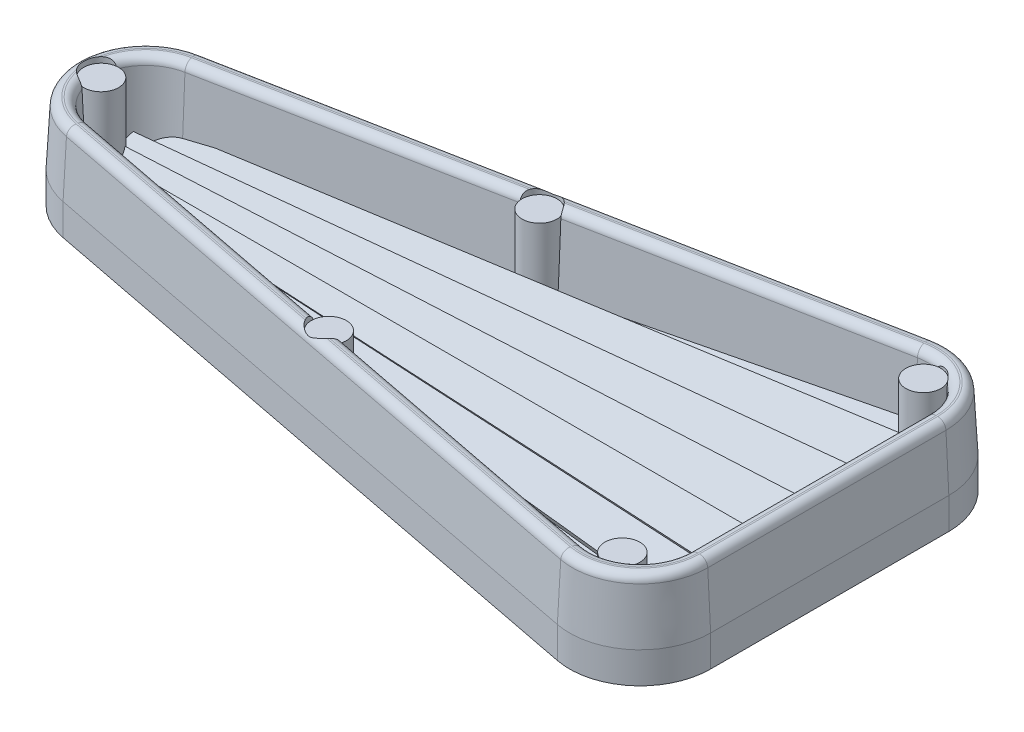
from build123d import *

# Parameters (mm, degrees)
BOSS_EXTRUDE1_DEPTH = 3.4544
CUT_EXTRUDE1_DEPTH  = 73.37481788
CUT_EXTRUDE2_DEPTH  = 73.37481788
CUT_EXTRUDE3_DEPTH  = 73.37481788
CUT_EXTRUDE4_DEPTH  = 73.37481788
EXTRUDE_THIN1_DEPTH = 6.35
DRAFT1_ANGLE        = -3
FILLET1_R           = 0.5588
SKETCH9_R           = 1.1811
BOSS_EXTRUDE2_DEPTH = 5.08
SKETCH10_R          = 1.1811
CUT_EXTRUDE5_DEPTH  = 0.381


with BuildPart() as part:
    # Sketch1 → Boss-Extrude1 (new body)
    with BuildSketch(Plane(origin=(0, 0, 0), x_dir=(1, 0, 0), z_dir=(0, 1, 0))):
        with BuildLine():
            Line((24.077556442, 4.675181972), (65.479556442, 12.714281972))
            ThreePointArc((65.479556442, 12.714281972), (69.417036576, 11.713657695), (71.149844843, 8.0391))
            Line((71.149844843, 8.0391), (71.149844843, -8.0391))
            ThreePointArc((71.149844843, -8.0391), (69.417036576, -11.713657695), (65.479556442, -12.714281972))
            Line((65.479556442, -12.714281972), (24.077556442, -4.675181972))
            ThreePointArc((24.077556442, -4.675181972), (20.222844843, 0), (24.077556442, 4.675181972))
        make_face()
    extrude(amount=BOSS_EXTRUDE1_DEPTH)

    # Sketch2 → Cut-Extrude1 (cut, through all)
    with BuildSketch(Plane(origin=(0, 0, 0), x_dir=(0, 0, -1), z_dir=(1, 0, 0))):
        Polygon((-1.905, 3.4544), (0, 1.5494), (1.905, 3.4544), align=None)
    extrude(amount=CUT_EXTRUDE1_DEPTH, mode=Mode.SUBTRACT)

    # Sketch3 → Cut-Extrude2 (cut, through all)
    with BuildSketch(Plane(origin=(0, 0, 0), x_dir=(-0.052335956242944376, 0, -0.9986295347545739), z_dir=(0.9986295347545738, 0, -0.05233595624294437))):
        Polygon((1.905, 3.4544), (-1.905, 3.4544), (0, 1.5494), align=None)
    cut_extrude2 = extrude(amount=CUT_EXTRUDE2_DEPTH, mode=Mode.SUBTRACT)

    # Sketch4 → Cut-Extrude3 (cut, through all)
    with BuildSketch(Plane(origin=(0, 0, 0), x_dir=(-0.1045284632676543, 0, -0.9945218953682733), z_dir=(0.9945218953682734, 0, -0.10452846326765432))):
        Polygon((1.905, 3.4544), (-1.905, 3.4544), (0, 1.5494), align=None)
    cut_extrude3 = extrude(amount=CUT_EXTRUDE3_DEPTH, mode=Mode.SUBTRACT)

    # Sketch5 → Cut-Extrude4 (cut, through all)
    with BuildSketch(Plane(origin=(0, 0, 0), x_dir=(-0.15643446504023115, 0, -0.9876883405951378), z_dir=(0.9876883405951378, 0, -0.15643446504023115))):
        Polygon((0, 1.5494), (1.905, 3.4544), (-1.905, 3.4544), align=None)
    cut_extrude4 = extrude(amount=CUT_EXTRUDE4_DEPTH, mode=Mode.SUBTRACT)

    # Mirror1: Cut-Extrude2, Cut-Extrude3, Cut-Extrude4 across plane
    add(cut_extrude2.mirror(Plane.XY), mode=Mode.SUBTRACT)
    add(cut_extrude3.mirror(Plane.XY), mode=Mode.SUBTRACT)
    add(cut_extrude4.mirror(Plane.XY), mode=Mode.SUBTRACT)

    # Sketch6 → Extrude-Thin1 (add)
    with BuildSketch(Plane.XZ):
        with BuildLine():
            Line((71.149844843, -8.0391), (71.149844843, 8.0391))
            ThreePointArc((71.149844843, 8.0391), (69.417036576, 11.713657695), (65.479556442, 12.714281972))
            Line((65.479556442, 12.714281972), (24.077556442, 4.675181972))
            ThreePointArc((24.077556442, 4.675181972), (20.222844843, 0), (24.077556442, -4.675181972))
            Line((24.077556442, -4.675181972), (65.479556442, -12.714281972))
            ThreePointArc((65.479556442, -12.714281972), (69.417036576, -11.713657695), (71.149844843, -8.0391))
        make_face()
        with BuildLine():
            Line((69.422644843, -8.0391), (69.422644843, 8.0391))
            ThreePointArc((69.422644843, 8.0391), (68.318268374, 10.381018104), (65.808781035, 11.01874931))
            Line((65.808781035, 11.01874931), (24.406781035, 2.97964931))
            ThreePointArc((24.406781035, 2.97964931), (21.950044843, 0), (24.406781035, -2.97964931))
            Line((24.406781035, -2.97964931), (65.808781035, -11.01874931))
            ThreePointArc((65.808781035, -11.01874931), (68.318268374, -10.381018104), (69.422644843, -8.0391))
        make_face(mode=Mode.SUBTRACT)
    extrude(amount=-EXTRUDE_THIN1_DEPTH)

    # Cut-Sweep1: sweep along a path in Sketch8
    with BuildLine(Plane(origin=(0, 6.35, 0), x_dir=(1, 0, 0), z_dir=(0, 1, 0))) as cut_sweep1_path:
        Line((65.479556442, -12.714281972), (24.077556442, -4.675181972))
        ThreePointArc((24.077556442, -4.675181972), (20.222844843, 0), (24.077556442, 4.675181972))
        Line((24.077556442, 4.675181972), (65.479556442, 12.714281972))
        ThreePointArc((65.479556442, 12.714281972), (69.417036576, 11.713657695), (71.149844843, 8.0391))
        Line((71.149844843, 8.0391), (71.149844843, -8.0391))
        ThreePointArc((71.149844843, -8.0391), (69.417036576, -11.713657695), (65.479556442, -12.714281972))
    # Sketch7 → Cut-Sweep1 (sweep, cut)
    with BuildSketch(Plane.XY):
        Polygon((71.149844843, 6.35), (71.149844843, 2.1082), (70.927541525, 6.35), align=None)
    sweep(path=cut_sweep1_path.line, mode=Mode.SUBTRACT)

    # Draft1
    draft1_faces = [part.faces().sort_by_distance(p)[0] for p in [
        (45.346144033, 4.124495993, 7.045482677),
        (68.318268374, 3.949699995, 10.381018104),
        (69.422644843, 4.344366116, 0),
        (68.318268374, 3.949699995, -10.381018104),
        (45.346144033, 4.124495993, -7.045482677),
        (21.950044843, 3.949699987, 0),
    ]]
    draft(draft1_faces, Plane(origin=(66.387344843, 0, 8.0391), x_dir=(0, 0, -1), z_dir=(0, -1, 0)), DRAFT1_ANGLE)

    # Fillet1
    fillet1_edges = [part.edges().sort_by_distance(p)[0] for p in [
        (68.529974262, 6.35, 10.637785316),
        (69.755434242, 6.35, 0),
        (68.529974262, 6.35, -10.637785316),
        (45.04434747, 6.35, -7.325887183),
        (21.617255445, 6.35, 0),
        (69.275617043, 6.35, 11.542137198),
        (70.927541525, 6.35, 0),
        (69.275617043, 6.35, -11.542137198),
        (44.820930064, 6.35, -8.476504472),
        (20.445148161, 6.35, 0),
        (45.04434747, 6.35, 7.325887183),
        (44.820930064, 6.35, 8.476504472),
    ]]
    fillet(fillet1_edges, radius=FILLET1_R)

    # Sketch9 → Boss-Extrude2 (add)
    with BuildSketch(Plane(origin=(0, 6.35, 0), x_dir=(1, 0, 0), z_dir=(0, 1, 0))):
        with Locations((21.969609604, 0)):
            Circle(SKETCH9_R)
        with Locations((44.45, -7.112)):
            Circle(SKETCH9_R)
        with Locations(Location((67.31, -10.16, 0), (0, 0, 270))):
            Circle(SKETCH9_R)
        with Locations((44.45, 7.112)):
            Circle(SKETCH9_R)
        with Locations(Location((67.31, 10.16, 0), (0, 0, 11.250596394))):
            Circle(SKETCH9_R)
    extrude(amount=-BOSS_EXTRUDE2_DEPTH)

    # Sketch10 → Cut-Extrude5 (cut)
    with BuildSketch(Plane(origin=(0, 6.35, 0), x_dir=(1, 0, 0), z_dir=(0, 1, 0))):
        with Locations((44.45, -7.112)):
            Circle(SKETCH10_R)
        with Locations((67.31, -10.16)):
            Circle(SKETCH10_R)
        with Locations((67.31, 10.16)):
            Circle(SKETCH10_R)
        with Locations((44.45, 7.112)):
            Circle(SKETCH10_R)
        with Locations((21.969609604, 0)):
            Circle(SKETCH10_R)
    extrude(amount=-CUT_EXTRUDE5_DEPTH, mode=Mode.SUBTRACT)


solid = part.part
